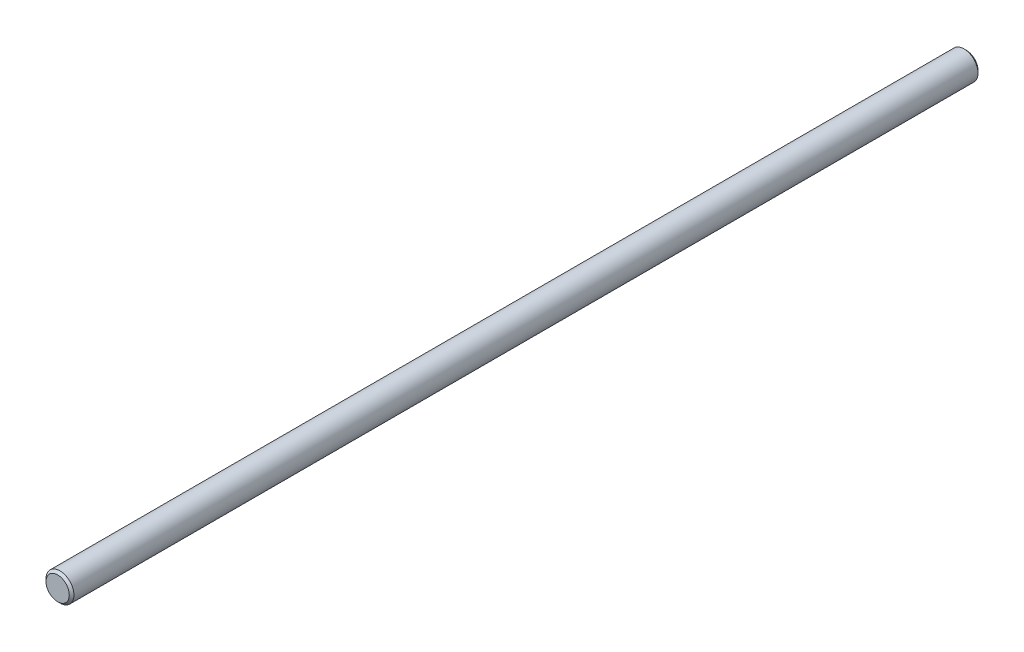
from build123d import *

# Parameters (mm, degrees)
SCHIZZO1_R                   = 6
ESTRUSIONE_ESTRUSIONE1_DEPTH = 390
SMUSSO1_SIZE                 = 1


with BuildPart() as part:
    # Schizzo1 → Estrusione-Estrusione1 (new body)
    with BuildSketch(Plane.XY):
        Circle(SCHIZZO1_R)
    extrude(amount=ESTRUSIONE_ESTRUSIONE1_DEPTH)

    # Smusso1
    smusso1_edges = [part.edges().sort_by_distance(p)[0] for p in [
        (-6, 0, 0),
        (-6, 0, 390),
    ]]
    chamfer(smusso1_edges, length=SMUSSO1_SIZE)


solid = part.part
